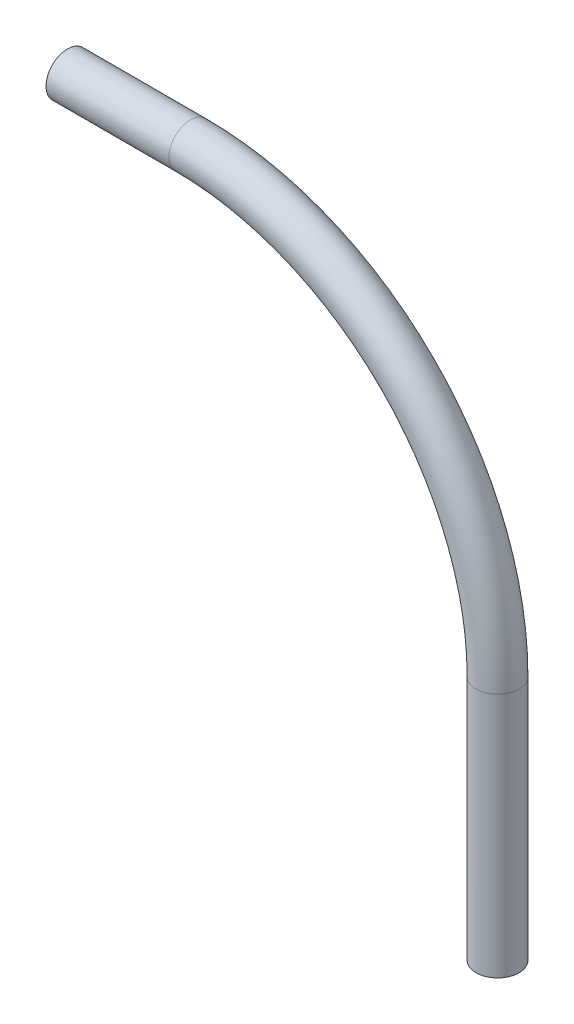
from build123d import *

# Parameters (mm, degrees)
SKIZZE2_R = 3.5


with BuildPart() as part:
    # Austragung1: sweep along a path in Skizze1
    with BuildLine(Plane.XY) as austragung1_path:
        Line((0, 0), (20, 0))
        ThreePointArc((20, 0), (55.355339059, -14.644660941), (70, -50))
        Line((70, -50), (70, -90))
    # Skizze2 → Austragung1 (sweep)
    with BuildSketch(Plane(origin=(0, 0, 0), x_dir=(0, 0, -1), z_dir=(1, 0, 0))):
        Circle(SKIZZE2_R)
    sweep(path=austragung1_path.line)


solid = part.part
